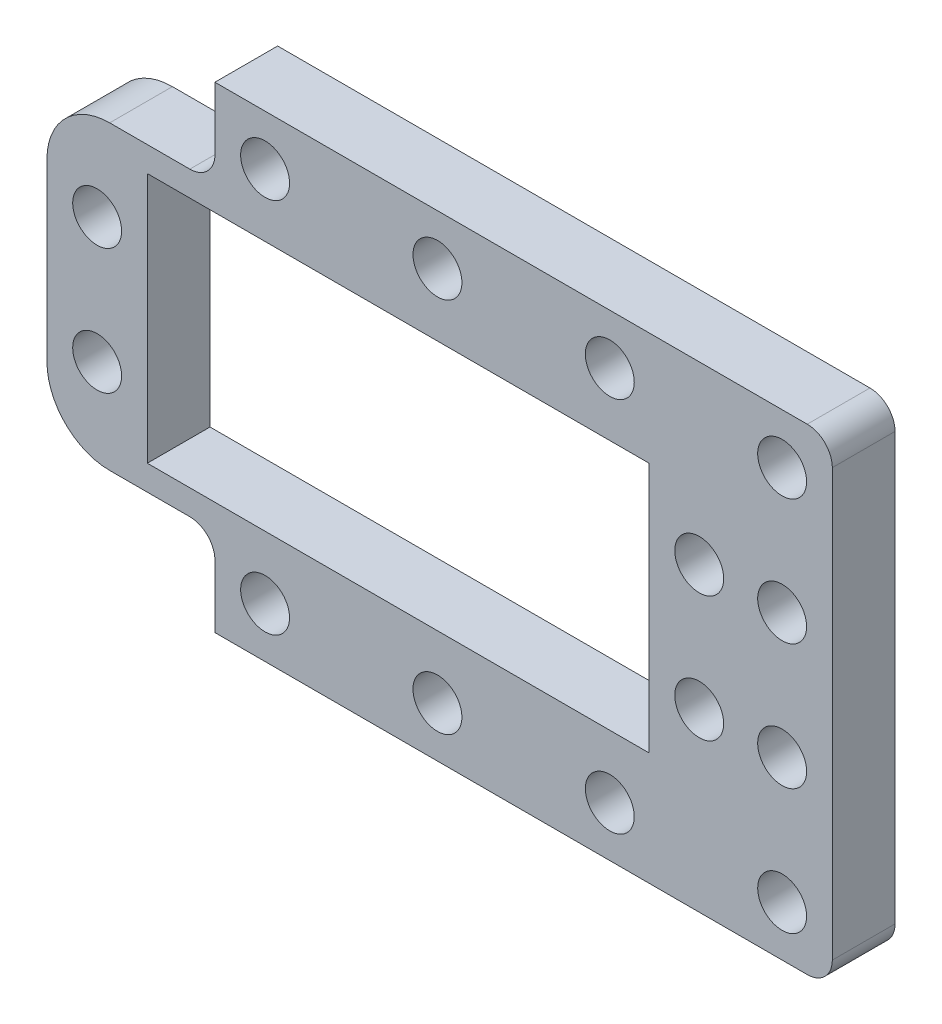
from build123d import *

# Parameters (mm, degrees)
SKETCH1_R           = 1.95
SKETCH1_W           = 40
SKETCH1_H           = 20
BOSS_EXTRUDE1_DEPTH = 5
SKETCH2_W           = 13.39
SKETCH2_H           = 7
CUT_EXTRUDE2_DEPTH  = 6
FILLET1_R           = 2
FILLET2_R           = 5


with BuildPart() as part:
    # Sketch1 → Boss-Extrude1 (new body)
    with BuildSketch(Plane.XY):
        with BuildLine():
            Line((-2, 0), (-60.61, 0))
            ThreePointArc((-60.61, 0), (-62.024213562, -0.585786438), (-62.61, -2))
            Line((-62.61, -2), (-62.61, -36))
            ThreePointArc((-62.61, -36), (-62.024213562, -37.414213562), (-60.61, -38))
            Line((-60.61, -38), (-2, -38))
            ThreePointArc((-2, -38), (-0.585786438, -37.414213562), (0, -36))
            Line((0, -36), (0, -2))
            ThreePointArc((0, -2), (-0.585786438, -0.585786438), (-2, 0))
        make_face()
        with Locations((-10.61, -14)):
            Circle(SKETCH1_R, mode=Mode.SUBTRACT)
        with Locations((-10.61, -24)):
            Circle(SKETCH1_R, mode=Mode.SUBTRACT)
        with Locations((-58.61, -24)):
            Circle(SKETCH1_R, mode=Mode.SUBTRACT)
        with Locations((-58.61, -14)):
            Circle(SKETCH1_R, mode=Mode.SUBTRACT)
        with Locations((-45.22, -4)):
            Circle(SKETCH1_R, mode=Mode.SUBTRACT)
        with Locations((-4, -4)):
            Circle(SKETCH1_R, mode=Mode.SUBTRACT)
        with Locations((-4, -14)):
            Circle(SKETCH1_R, mode=Mode.SUBTRACT)
        with Locations((-58.61, -4)):
            Circle(SKETCH1_R, mode=Mode.SUBTRACT)
        with Locations((-31.48, -4)):
            Circle(SKETCH1_R, mode=Mode.SUBTRACT)
        with Locations((-17.74, -4)):
            Circle(SKETCH1_R, mode=Mode.SUBTRACT)
        with Locations((-45.22, -34)):
            Circle(SKETCH1_R, mode=Mode.SUBTRACT)
        with Locations((-58.61, -34)):
            Circle(SKETCH1_R, mode=Mode.SUBTRACT)
        with Locations((-4, -34)):
            Circle(SKETCH1_R, mode=Mode.SUBTRACT)
        with Locations((-17.74, -34)):
            Circle(SKETCH1_R, mode=Mode.SUBTRACT)
        with Locations((-31.48, -34)):
            Circle(SKETCH1_R, mode=Mode.SUBTRACT)
        with Locations((-4, -24)):
            Circle(SKETCH1_R, mode=Mode.SUBTRACT)
        with Locations((-34.61, -19)):
            Rectangle(SKETCH1_W, SKETCH1_H, mode=Mode.SUBTRACT)
    extrude(amount=BOSS_EXTRUDE1_DEPTH)

    # Sketch2 → Cut-Extrude2 (cut, through all)
    with BuildSketch(Plane.XY.offset(5)):
        with Locations((-55.915, -3.5)):
            Rectangle(SKETCH2_W, SKETCH2_H)
        with Locations((-55.915, -34.5)):
            Rectangle(SKETCH2_W, SKETCH2_H)
    extrude(amount=-CUT_EXTRUDE2_DEPTH, mode=Mode.SUBTRACT)

    # Fillet1
    fillet1_edges = [part.edges().sort_by_distance(p)[0] for p in [
        (-49.22, -7, 2.5),
        (-49.22, -31, 2.5),
    ]]
    fillet(fillet1_edges, radius=FILLET1_R)

    # Fillet2
    fillet2_edges = [part.edges().sort_by_distance(p)[0] for p in [
        (-62.61, -7, 2.5),
        (-62.61, -31, 2.5),
    ]]
    fillet(fillet2_edges, radius=FILLET2_R)


solid = part.part
